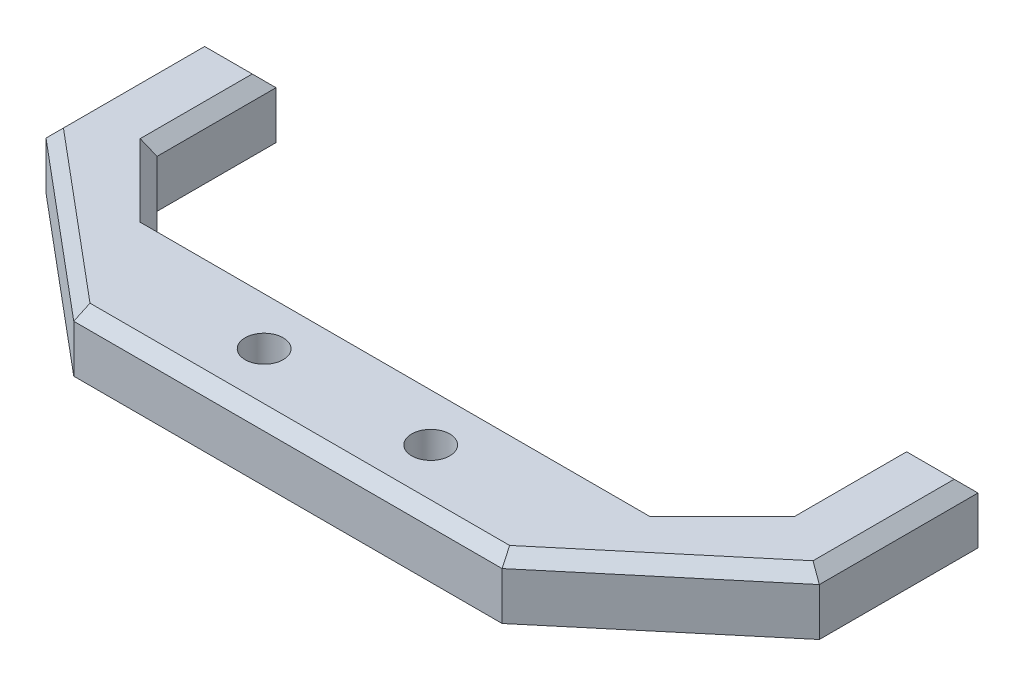
from build123d import *

# Parameters (mm, degrees)
EXTRUDE_1_DEPTH     = 5
SKETCH_7_R          = 1.6
CUT_EXTRUDE_1_DEPTH = 6
CHAMFER_1_SIZE      = 1


with BuildPart() as part:
    # 草图1 → 凸台-拉伸1 (new body)
    with BuildSketch(Plane(origin=(0, 0, 0), x_dir=(1, 0, 0), z_dir=(0, 1, 0))):
        Polygon((-21, 0), (21, 0), (26.5, 5.5), (26.5, 15.5), (32.5, 15.5), (32.5, 2.166944652), (18, -10), (-18, -10), (-32.5, 2.166944652), (-32.5, 15.5), (-26.5, 15.5), (-26.5, 5.5), align=None)
    extrude(amount=EXTRUDE_1_DEPTH)

    # 草图7 → 切除-拉伸1 (cut, through all)
    with BuildSketch(Plane(origin=(0, 5, 0), x_dir=(1, 0, 0), z_dir=(0, 1, 0))):
        with Locations((-7, -5)):
            Circle(SKETCH_7_R)
        with Locations((7, -5)):
            Circle(SKETCH_7_R)
    extrude(amount=-CUT_EXTRUDE_1_DEPTH, mode=Mode.SUBTRACT)

    # 倒角1
    chamfer_1_edges = [part.edges().sort_by_distance(p)[0] for p in [
        (-23.75, 5, -2.75),
        (-26.5, 5, -10.5),
        (-29.5, 5, -15.5),
        (-32.5, 5, -8.833472326),
        (-25.25, 5, 3.916527674),
        (0, 5, 10),
        (25.25, 5, 3.916527674),
        (32.5, 5, -8.833472326),
        (29.5, 5, -15.5),
        (26.5, 5, -10.5),
        (23.75, 5, -2.75),
        (0, 5, 0),
    ]]
    chamfer(chamfer_1_edges, length=CHAMFER_1_SIZE)


solid = part.part
